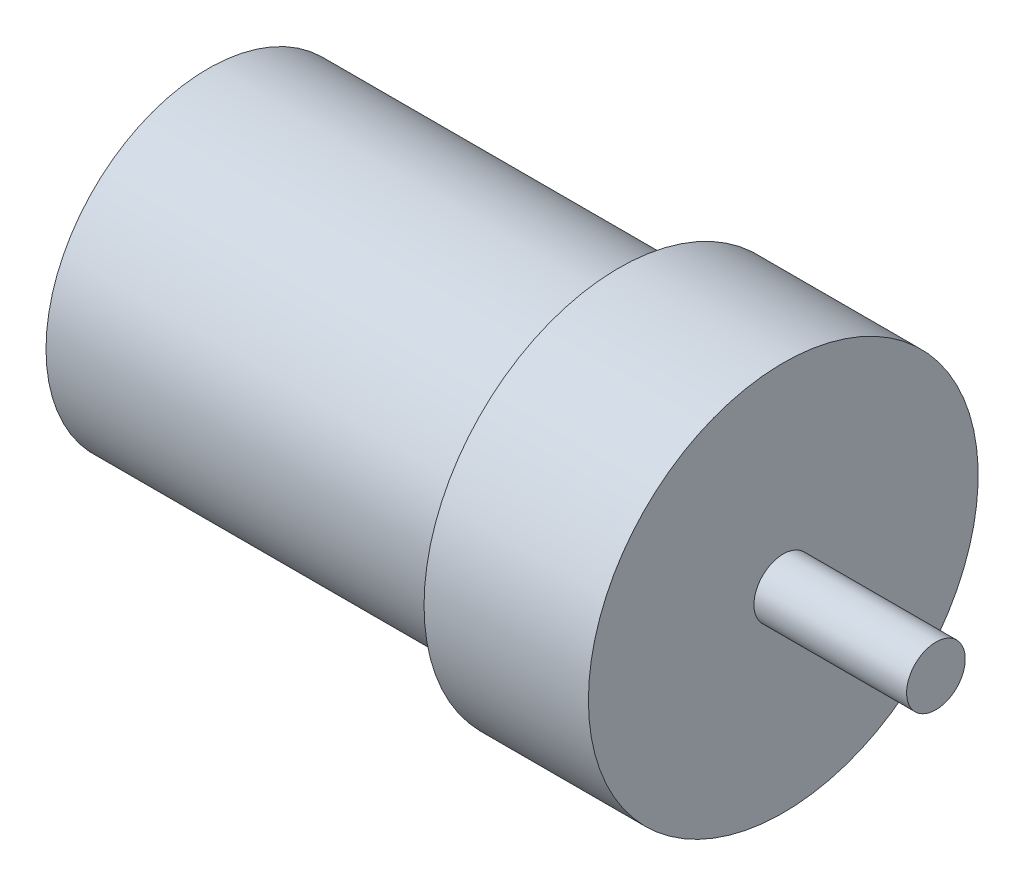
from build123d import *


with BuildPart() as part:
    # Sketch1 → Revolve1 (revolve)
    with BuildSketch(Plane.XY):
        Polygon((0, 9.525), (0, 17.526), (44.45, 17.526), (44.45, 21.082), (62.23, 21.082), (62.23, 3.175), (78.74, 3.175), (78.74, 0), (45.72, 0), (45.72, 9.525), align=None)
    revolve(axis=Axis((-31.81268841, 0, 0), (1, 0, 0)))


solid = part.part
